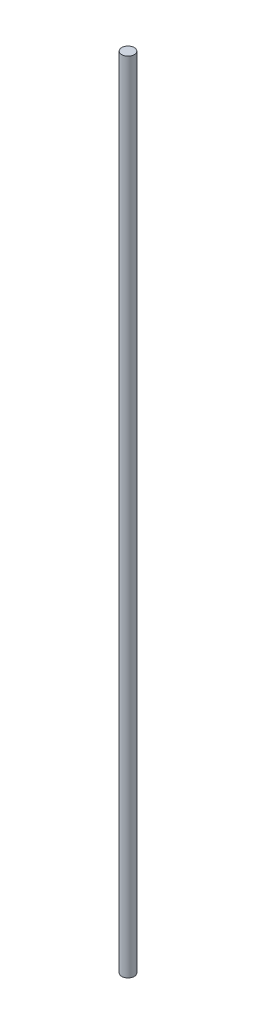
from build123d import *

# Parameters (mm, degrees)
SKETCH1_R           = 2.38125
BOSS_EXTRUDE1_DEPTH = 304.8


with BuildPart() as part:
    # Sketch1 → Boss-Extrude1 (new body)
    with BuildSketch(Plane(origin=(0, 0, 0), x_dir=(1, 0, 0), z_dir=(0, 1, 0))):
        Circle(SKETCH1_R)
    extrude(amount=BOSS_EXTRUDE1_DEPTH)


solid = part.part
